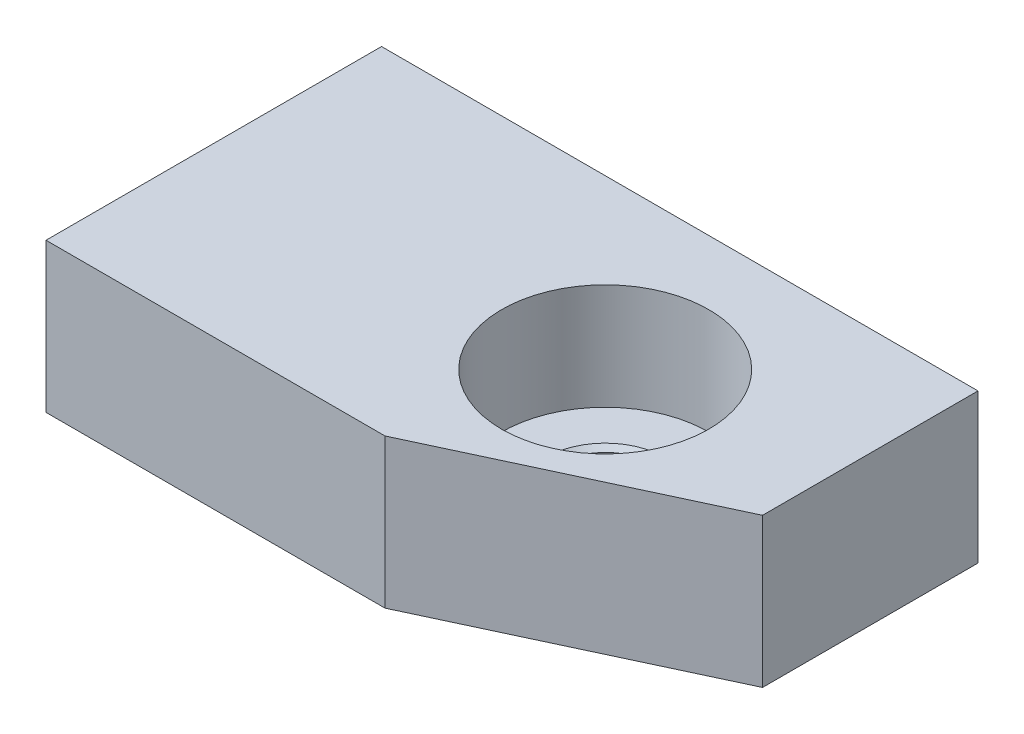
from build123d import *

# Parameters (mm, degrees)
EXTRUDE_1_DEPTH = 4


with BuildPart() as part:
    # Эскиз1 → Бобышка-Вытянуть1 (new body)
    with BuildSketch(Plane(origin=(0, 0, 0), x_dir=(1, 0, 0), z_dir=(0, 1, 0))):
        Polygon((0, 0), (0, -9), (9.093856713, -9), (16, -5.779612497), (16, 0), align=None)
    extrude(amount=EXTRUDE_1_DEPTH)

    # Эскиз2 → Цековка для  винта с внутренним шестигранником #41 (revolve, cut)
    with BuildSketch(Plane(origin=(10.5, 4, 4.5), x_dir=(0, 0, 1), z_dir=(1, 0, 0))):
        Polygon((0, 0), (0, 4), (1.6002, 4), (1.4732, 3.873), (1.4732, 2.9718), (1.6002, 2.8448), (2.77876, 2.8448), (2.77876, 0), align=None)
    revolve(axis=Axis((10.5, 10.35, 4.5), (0, -1, 0)), mode=Mode.SUBTRACT)


solid = part.part
